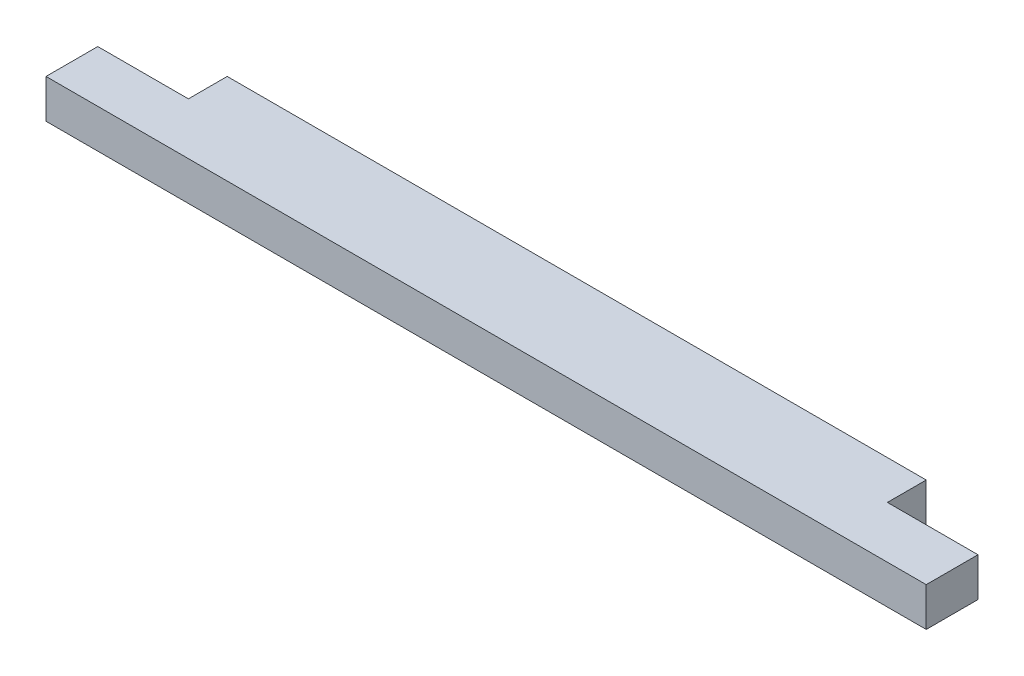
from build123d import *

# Parameters (mm, degrees)
SKETCH1_W           = 863.6
SKETCH1_H           = 88.9
BOSS_EXTRUDE1_DEPTH = 38.1
SKETCH3_W           = 88.9
SKETCH3_H           = 38.1
CUT_EXTRUDE1_DEPTH  = 39.1


with BuildPart() as part:
    # Sketch1 → Boss-Extrude1 (new body)
    with BuildSketch(Plane(origin=(0, 0, 0), x_dir=(1, 0, 0), z_dir=(0, 1, 0))):
        with Locations((431.8, 44.45)):
            Rectangle(SKETCH1_W, SKETCH1_H)
    extrude(amount=BOSS_EXTRUDE1_DEPTH)

    # Sketch3 → Cut-Extrude1 (cut, through all)
    with BuildSketch(Plane(origin=(0, 38.1, 0), x_dir=(1, 0, 0), z_dir=(0, 1, 0))):
        with Locations((819.15, 69.85)):
            Rectangle(SKETCH3_W, SKETCH3_H)
        with Locations((44.45, 69.85)):
            Rectangle(SKETCH3_W, SKETCH3_H)
    extrude(amount=-CUT_EXTRUDE1_DEPTH, mode=Mode.SUBTRACT)


solid = part.part
